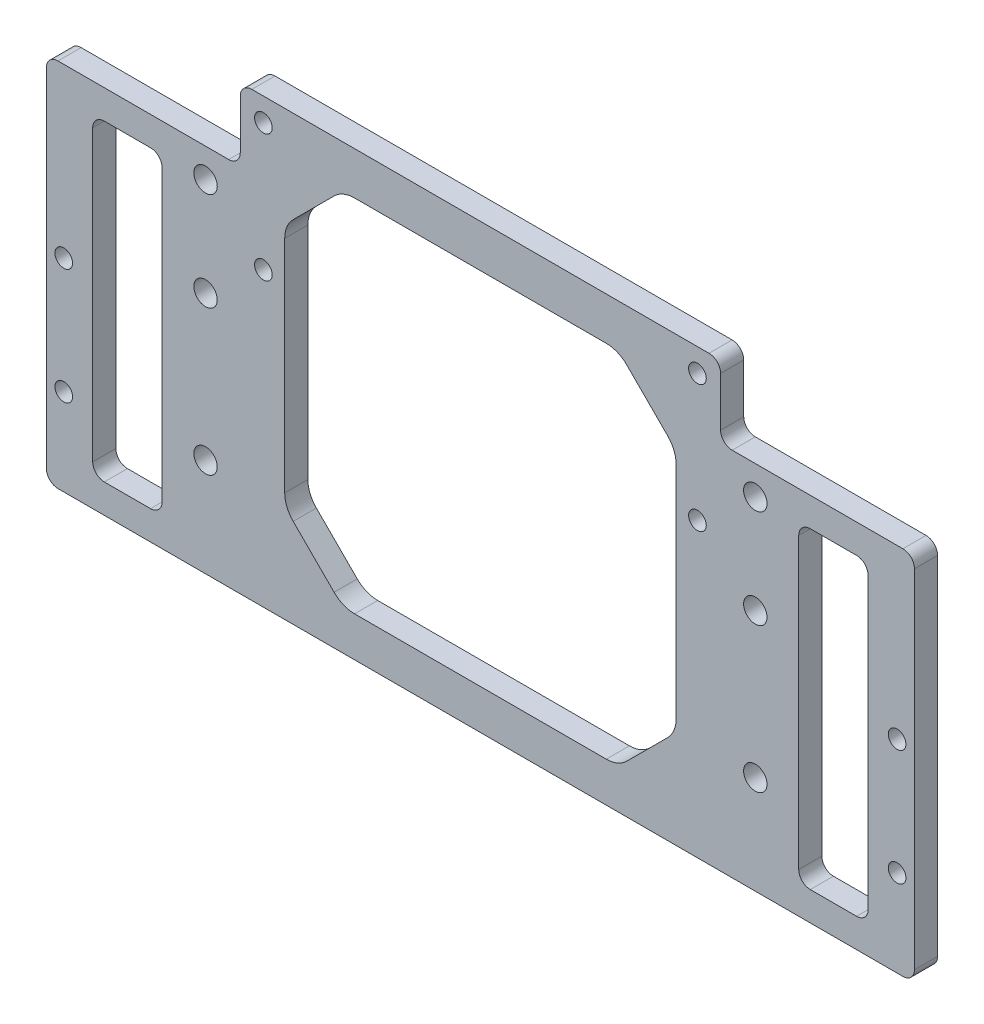
from build123d import *

# Parameters (mm, degrees)
SKETCH_1_W          = 105
SKETCH_1_H          = 52
SKETCH_1_R          = 2.025
SKETCH_1_R_2        = 1.525
SKETCH_1_W_2        = 83
SKETCH_1_H_2        = 12.5
EXTRUDE_3_DEPTH     = 4
SKETCH_3_W          = 105
SKETCH_3_H          = 12
EXTRUDE_4_DEPTH     = 4
SKETCH_6_W          = 67.640689882
SKETCH_6_H          = 62.229434692
CUT_EXTRUDE_1_DEPTH = 4
CHAMFER_1_SIZE      = 10
FILLET_2_R          = 5
SKETCH_7_W          = 20
SKETCH_7_H          = 64
SKETCH_7_R          = 1.525
EXTRUDE_5_DEPTH     = 4
SKETCH_8_W          = 12
SKETCH_8_H          = 54
CUT_EXTRUDE_2_DEPTH = 10
FILLET_3_R          = 2


with BuildPart() as part:
    # 草图1 → 凸台-拉伸3 (new body)
    with BuildSketch(Plane.XY):
        Rectangle(SKETCH_1_W, SKETCH_1_H)
        with Locations((-47.5, 4)):
            Circle(SKETCH_1_R, mode=Mode.SUBTRACT)
        with Locations((-47.5, 21)):
            Circle(SKETCH_1_R, mode=Mode.SUBTRACT)
        with Locations((-47.5, -21)):
            Circle(SKETCH_1_R, mode=Mode.SUBTRACT)
        with Locations((47.5, 21)):
            Circle(SKETCH_1_R, mode=Mode.SUBTRACT)
        with Locations((47.5, 4)):
            Circle(SKETCH_1_R, mode=Mode.SUBTRACT)
        with Locations((47.5, -21)):
            Circle(SKETCH_1_R, mode=Mode.SUBTRACT)
        with Locations((-37.5, 12.5)):
            Circle(SKETCH_1_R_2, mode=Mode.SUBTRACT)
        with Locations((37.5, 12.5)):
            Circle(SKETCH_1_R_2, mode=Mode.SUBTRACT)
        with Locations((0, 32.25)):
            Rectangle(SKETCH_1_W_2, SKETCH_1_H_2)
        with Locations((-37.5, 34.5)):
            Circle(SKETCH_1_R_2, mode=Mode.SUBTRACT)
        with Locations((37.5, 34.5)):
            Circle(SKETCH_1_R_2, mode=Mode.SUBTRACT)
    extrude(amount=EXTRUDE_3_DEPTH)

    # 草图3 → 凸台-拉伸4 (add)
    with BuildSketch(Plane.XY.offset(4)):
        with Locations((0, -32)):
            Rectangle(SKETCH_3_W, SKETCH_3_H)
        Polygon((-52.5, -26), (-52.5, 26), (-55, 26), (-55, -38), (-52.5, -38), align=None)
        Polygon((52.5, -38), (55, -38), (55, 26), (52.5, 26), (52.5, -26), align=None)
    extrude(amount=-EXTRUDE_4_DEPTH)

    # 草图6 → 切除-拉伸1 (cut)
    with BuildSketch(Plane(origin=(0, 0, 0), x_dir=(-1, 0, 0), z_dir=(0, 0, -1))):
        Rectangle(SKETCH_6_W, SKETCH_6_H)
    extrude(amount=-CUT_EXTRUDE_1_DEPTH, mode=Mode.SUBTRACT)

    # 倒角1
    chamfer_1_edges = [part.edges().sort_by_distance(p)[0] for p in [
        (-33.820344941, -31.114717346, 2),
        (33.820344941, -31.114717346, 2),
        (33.820344941, 31.114717346, 2),
        (-33.820344941, 31.114717346, 2),
    ]]
    chamfer(chamfer_1_edges, length=CHAMFER_1_SIZE)

    # 圆角2
    fillet_2_edges = [part.edges().sort_by_distance(p)[0] for p in [
        (-33.820344941, 21.114717346, 2),
        (-33.820344941, -21.114717346, 2),
        (23.820344941, -31.114717346, 2),
        (-23.820344941, -31.114717346, 2),
        (23.820344941, 31.114717346, 2),
        (-23.820344941, 31.114717346, 2),
        (33.820344941, -21.114717346, 2),
        (33.820344941, 21.114717346, 2),
    ]]
    fillet(fillet_2_edges, radius=FILLET_2_R)

    # 草图7 → 凸台-拉伸5 (add)
    with BuildSketch(Plane.XY.offset(4)):
        with Locations((-65, -6)):
            Rectangle(SKETCH_7_W, SKETCH_7_H)
        with Locations((-72, -3)):
            Circle(SKETCH_7_R, mode=Mode.SUBTRACT)
        with Locations((-72, -23)):
            Circle(SKETCH_7_R, mode=Mode.SUBTRACT)
        with Locations((65, -6)):
            Rectangle(SKETCH_7_W, SKETCH_7_H)
        with Locations((72, -23)):
            Circle(SKETCH_7_R, mode=Mode.SUBTRACT)
        with Locations((72, -3)):
            Circle(SKETCH_7_R, mode=Mode.SUBTRACT)
    extrude(amount=-EXTRUDE_5_DEPTH)

    # 草图8 → 切除-拉伸2 (cut)
    with BuildSketch(Plane.XY.offset(4)):
        with Locations((-61, -6)):
            Rectangle(SKETCH_8_W, SKETCH_8_H)
        with Locations((61, -6)):
            Rectangle(SKETCH_8_W, SKETCH_8_H)
    extrude(amount=-CUT_EXTRUDE_2_DEPTH, mode=Mode.SUBTRACT)

    # 圆角3
    fillet_3_edges = [part.edges().sort_by_distance(p)[0] for p in [
        (-75, 26, 2),
        (-75, -38, 2),
        (75, -38, 2),
        (75, 26, 2),
        (-67, -33, 2),
        (-67, 21, 2),
        (-55, 21, 2),
        (-55, -33, 2),
        (67, 21, 2),
        (67, -33, 2),
        (55, -33, 2),
        (55, 21, 2),
        (-41.5, 38.5, 2),
        (41.5, 38.5, 2),
        (41.5, 26, 2),
        (-41.5, 26, 2),
    ]]
    fillet(fillet_3_edges, radius=FILLET_3_R)


solid = part.part
